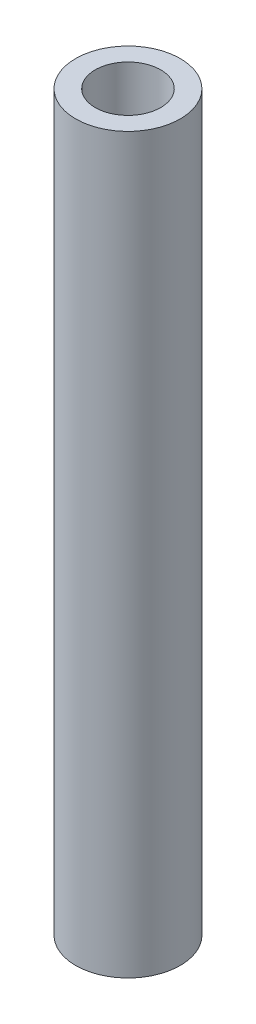
from build123d import *

# Parameters (mm, degrees)
SKETCH1_R           = 3.9751
SKETCH1_R_2         = 2.4892
BOSS_EXTRUDE1_DEPTH = 55.7276


with BuildPart() as part:
    # Sketch1 → Boss-Extrude1 (new body)
    with BuildSketch(Plane(origin=(0, 0, 0), x_dir=(1, 0, 0), z_dir=(0, 1, 0))):
        Circle(SKETCH1_R)
        Circle(SKETCH1_R_2, mode=Mode.SUBTRACT)
    extrude(amount=BOSS_EXTRUDE1_DEPTH)


solid = part.part
